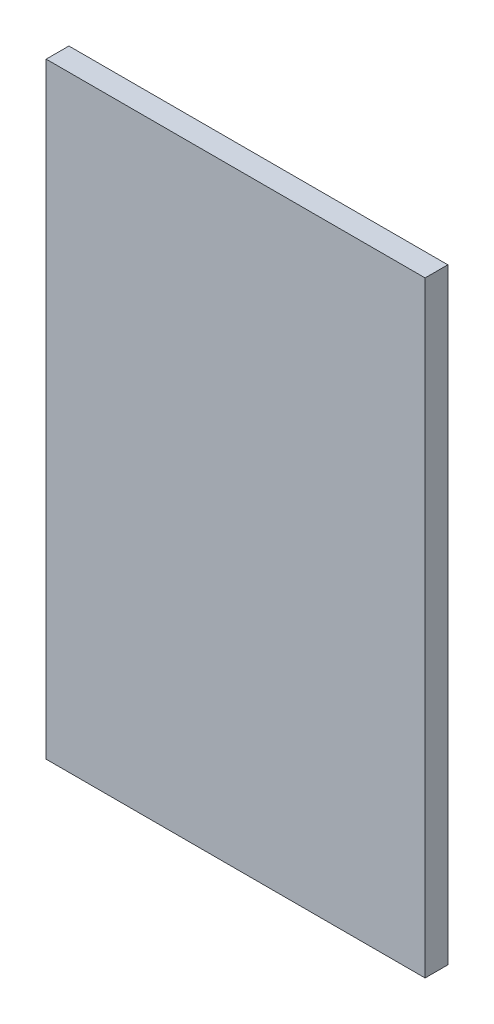
from build123d import *

# Parameters (mm, degrees)
SKETCH1_W           = 500
SKETCH1_H           = 30
BOSS_EXTRUDE1_DEPTH = 800


with BuildPart() as part:
    # Sketch1 → Boss-Extrude1 (new body)
    with BuildSketch(Plane(origin=(0, 0, 0), x_dir=(1, 0, 0), z_dir=(0, 1, 0))):
        Rectangle(SKETCH1_W, SKETCH1_H)
    extrude(amount=BOSS_EXTRUDE1_DEPTH)


solid = part.part
